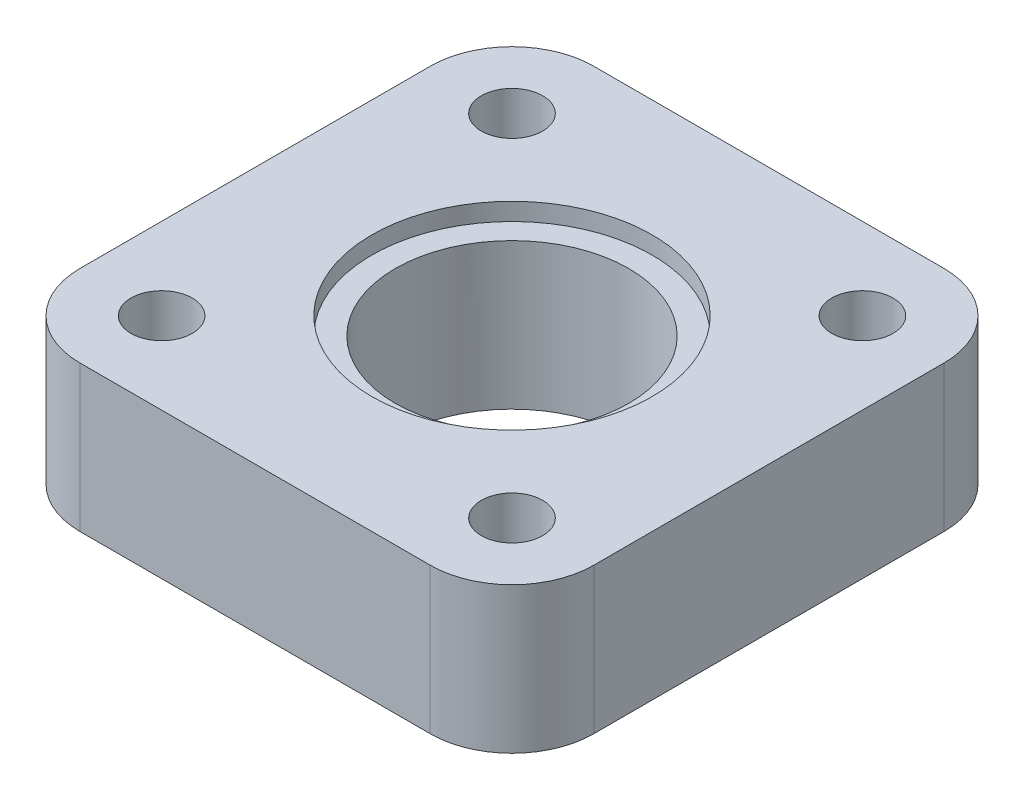
from build123d import *

# Parameters (mm, degrees)
ESQUISSE1_R             = 5.25
ESQUISSE1_R_2           = 20
BOSS_EXTRU_1_DEPTH      = 25
ESQUISSE2_R             = 24
ENL_V_MAT_EXTRU_1_DEPTH = 3
ESQUISSE3_R             = 23.5
ESQUISSE3_R_2           = 20
BOSS_EXTRU_2_DEPTH      = 3


with BuildPart() as part:
    # Esquisse1 → Boss.-Extru.1 (new body)
    with BuildSketch(Plane(origin=(0, 0, 0), x_dir=(1, 0, 0), z_dir=(0, 1, 0))):
        with BuildLine():
            Line((-44, 30), (-44, -30))
            ThreePointArc((-44, -30), (-39.899495706, -39.899494167), (-30.000002176, -44))
            Line((-30.000002176, -44), (30, -44))
            ThreePointArc((30, -44), (39.899494937, -39.899494937), (44, -30))
            Line((44, -30), (44, 30))
            ThreePointArc((44, 30), (39.899494937, 39.899494937), (30, 44))
            Line((30, 44), (-30.000002176, 44))
            ThreePointArc((-30.000002176, 44), (-39.899495706, 39.899494167), (-44, 30))
        make_face()
        with Locations(Location((-30, 30, 0), (0, 0, 270))):  # turned: the seam where the file's is
            Circle(ESQUISSE1_R, mode=Mode.SUBTRACT)
        with Locations(Location((30, 30, 0), (0, 0, 270))):  # turned: the seam where the file's is
            Circle(ESQUISSE1_R, mode=Mode.SUBTRACT)
        with Locations(Location((30, -30, 0), (0, 0, 270))):  # turned: the seam where the file's is
            Circle(ESQUISSE1_R, mode=Mode.SUBTRACT)
        with Locations(Location((-30, -30, 0), (0, 0, 270))):  # turned: the seam where the file's is
            Circle(ESQUISSE1_R, mode=Mode.SUBTRACT)
        with Locations(Location((0, 0, 0), (0, 0, 270))):  # turned: the seam where the file's is
            Circle(ESQUISSE1_R_2, mode=Mode.SUBTRACT)
    extrude(amount=BOSS_EXTRU_1_DEPTH)

    # Esquisse2 → Enlèv. mat.-Extru.1 (cut)
    with BuildSketch(Plane(origin=(0, 25, 0), x_dir=(1, 0, 0), z_dir=(0, 1, 0))):
        with Locations(Location((0, 0, 0), (0, 0, 270))):  # turned: the seam where the file's is
            Circle(ESQUISSE2_R)
    extrude(amount=-ENL_V_MAT_EXTRU_1_DEPTH, mode=Mode.SUBTRACT)

    # Esquisse3 → Boss.-Extru.2 (add)
    with BuildSketch(Plane.XZ):
        with Locations(Location((0, 0, 0), (0, 0, 90))):  # turned: the seam where the file's is
            Circle(ESQUISSE3_R)
        with Locations(Location((0, 0, 0), (0, 0, 270))):  # turned: the seam where the file's is
            Circle(ESQUISSE3_R_2, mode=Mode.SUBTRACT)
    extrude(amount=BOSS_EXTRU_2_DEPTH)


solid = part.part
